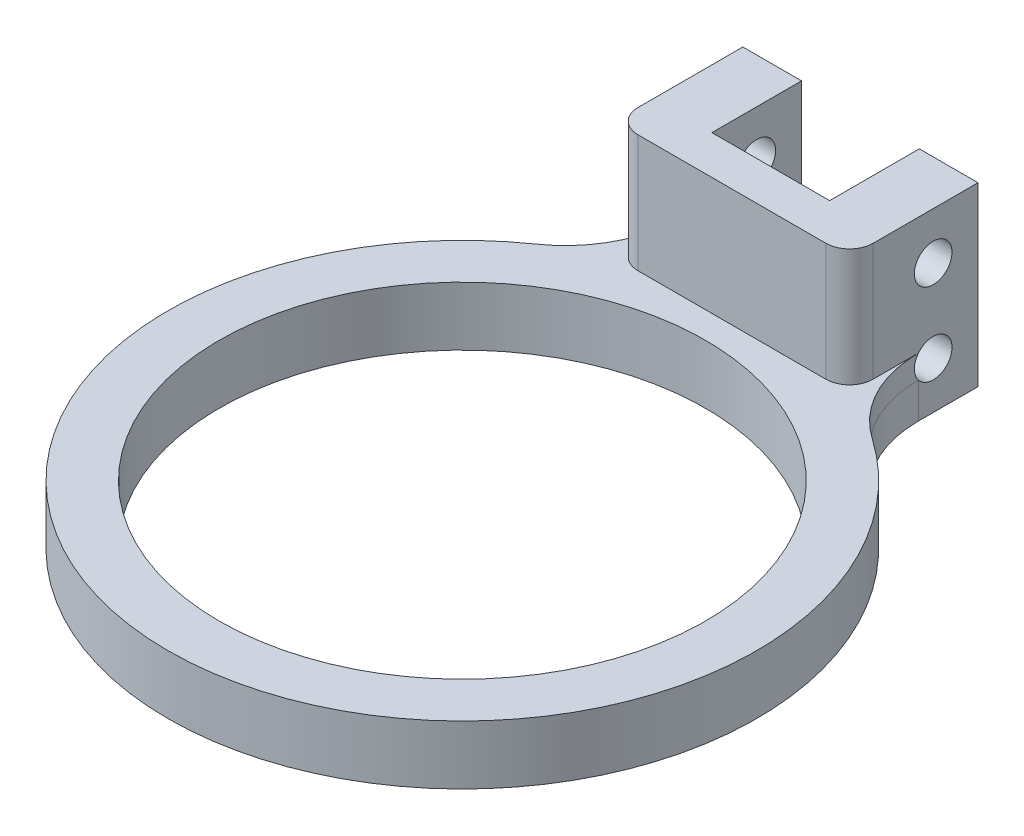
from build123d import *

# Parameters (mm, degrees)
SKETCH_1_R          = 25
SKETCH_1_R_2        = 20.65
EXTRUDE_1_DEPTH     = 5
EXTRUDE_2_DEPTH     = 15
SKETCH_3_R          = 1.6
CUT_EXTRUDE_1_DEPTH = 35.982946782
FILLET_1_R          = 10
FILLET_2_R          = 2


with BuildPart() as part:
    # 草图1 → 凸台-拉伸1 (new body)
    with BuildSketch(Plane(origin=(0, 0, 0), x_dir=(1, 0, 0), z_dir=(0, 1, 0))):
        Circle(SKETCH_1_R)
        Circle(SKETCH_1_R_2, mode=Mode.SUBTRACT)
    extrude(amount=EXTRUDE_1_DEPTH)

    # 草图2 → 凸台-拉伸2 (add)
    with BuildSketch(Plane(origin=(0, 0, 0), x_dir=(1, 0, 0), z_dir=(0, 1, 0))):
        Polygon((-5, 33.807000777), (-9.982946782, 33.807000777), (-9.982946782, 22.896387671), (9.982946782, 22.896387671), (9.982946782, 33.807000777), (5, 33.807000777), (5, 26.192999223), (-5, 26.192999223), align=None)
    extrude(amount=EXTRUDE_2_DEPTH)

    # 草图3 → 切除-拉伸1 (cut, through all)
    with BuildSketch(Plane.ZY.offset(9.982946782)):
        with Locations((-30, 4)):
            Circle(SKETCH_3_R)
        with Locations((-30, 11)):
            Circle(SKETCH_3_R)
    extrude(amount=-CUT_EXTRUDE_1_DEPTH, mode=Mode.SUBTRACT)

    # 圆角1
    fillet_1_edges = [part.edges().sort_by_distance(p)[0] for p in [
        (9.982946782, 2.5, -22.920313557),
        (-9.982946782, 2.5, -22.920313557),
    ]]
    fillet(fillet_1_edges, radius=FILLET_1_R)

    # 圆角2
    fillet_2_edges = [part.edges().sort_by_distance(p)[0] for p in [
        (-9.982946782, 10, -22.896387671),
        (9.982946782, 10, -22.896387671),
    ]]
    fillet(fillet_2_edges, radius=FILLET_2_R)


solid = part.part
